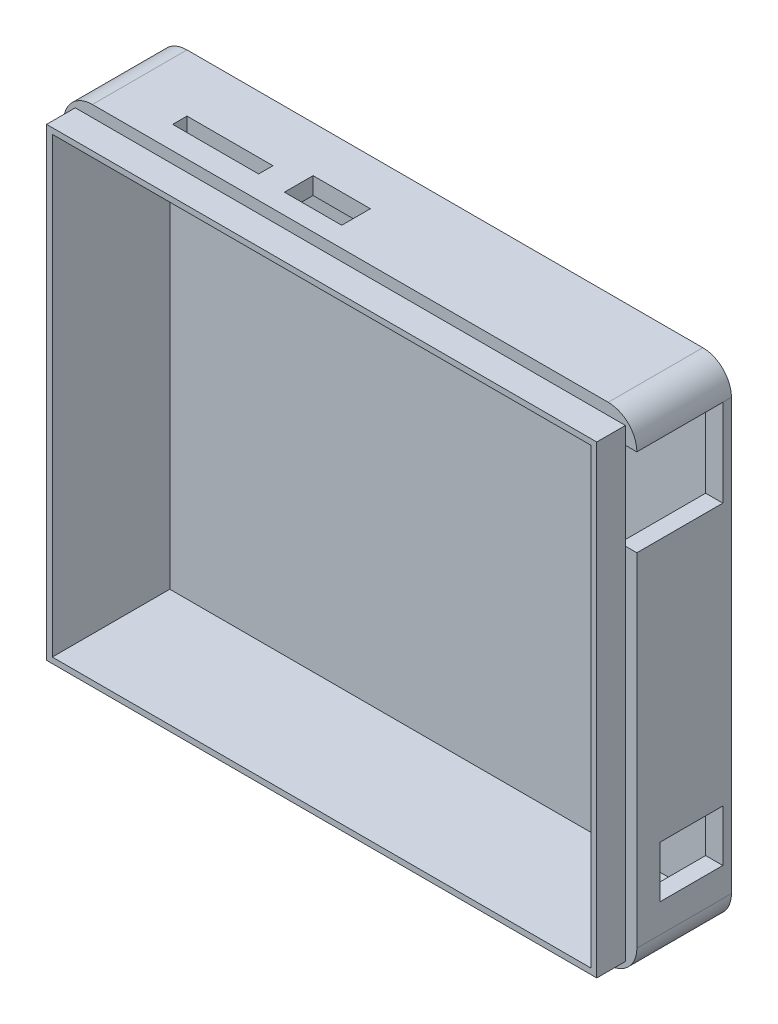
from build123d import *

# Parameters (mm, degrees)
SKETCH1_W           = 100
SKETCH1_H           = 85
BOSS_EXTRUDE2_DEPTH = 20
SKETCH3_W           = 100
SKETCH3_H           = 85
SKETCH3_W_2         = 96
SKETCH3_H_2         = 81
CUT_EXTRUDE1_DEPTH  = 5
SKETCH4_W           = 94
SKETCH4_H           = 79
CUT_EXTRUDE2_DEPTH  = 19
SKETCH9_W           = 100
SKETCH9_H           = 85
BOSS_EXTRUDE3_DEPTH = 1.5
SKETCH10_W          = 94
SKETCH10_H          = 79
CUT_EXTRUDE5_DEPTH  = 1.5
SKETCH11_W          = 11
SKETCH11_H          = 9
CUT_EXTRUDE7_DEPTH  = 50
SKETCH12_W          = 15
SKETCH12_H          = 15.24
CUT_EXTRUDE8_DEPTH  = 50
SKETCH13_W          = 15
SKETCH13_H          = 2.5
CUT_EXTRUDE9_DEPTH  = 50
SKETCH14_W          = 10
SKETCH14_H          = 5
CUT_EXTRUDE10_DEPTH = 50
FILLET1_R           = 5


with BuildPart() as part:
    # Sketch1 → Boss-Extrude2 (new body)
    with BuildSketch(Plane.XY):
        Rectangle(SKETCH1_W, SKETCH1_H)
    extrude(amount=BOSS_EXTRUDE2_DEPTH)

    # Sketch3 → Cut-Extrude1 (cut)
    with BuildSketch(Plane.XY.offset(20)):
        Rectangle(SKETCH3_W, SKETCH3_H)
        Rectangle(SKETCH3_W_2, SKETCH3_H_2, mode=Mode.SUBTRACT)
    extrude(amount=-CUT_EXTRUDE1_DEPTH, mode=Mode.SUBTRACT)

    # Sketch4 → Cut-Extrude2 (cut)
    with BuildSketch(Plane.XY.offset(20)):
        Rectangle(SKETCH4_W, SKETCH4_H)
    extrude(amount=-CUT_EXTRUDE2_DEPTH, mode=Mode.SUBTRACT)

    # Sketch9 → Boss-Extrude3 (add)
    with BuildSketch(Plane(origin=(0, 0, 0), x_dir=(-1, 0, 0), z_dir=(0, 0, -1))):
        Rectangle(SKETCH9_W, SKETCH9_H)
    extrude(amount=BOSS_EXTRUDE3_DEPTH)

    # Sketch10 → Cut-Extrude5 (cut)
    with BuildSketch(Plane.XY.offset(1)):
        Rectangle(SKETCH10_W, SKETCH10_H)
    extrude(amount=-CUT_EXTRUDE5_DEPTH, mode=Mode.SUBTRACT)

    # Sketch11 → Cut-Extrude7 (cut)
    with BuildSketch(Plane(origin=(50, 0, 0), x_dir=(0, 0, -1), z_dir=(1, 0, 0))):
        with Locations((-5.5, -28)):
            Rectangle(SKETCH11_W, SKETCH11_H)
    extrude(amount=-CUT_EXTRUDE7_DEPTH, mode=Mode.SUBTRACT)

    # Sketch12 → Cut-Extrude8 (cut)
    with BuildSketch(Plane(origin=(50, 0, 0), x_dir=(0, 0, -1), z_dir=(1, 0, 0))):
        with Locations((-7.5, 29.88)):
            Rectangle(SKETCH12_W, SKETCH12_H)
    extrude(amount=-CUT_EXTRUDE8_DEPTH, mode=Mode.SUBTRACT)

    # Sketch13 → Cut-Extrude9 (cut)
    with BuildSketch(Plane(origin=(0, 42.5, 0), x_dir=(1, 0, 0), z_dir=(0, 1, 0))):
        with Locations((-27.5, -9.75)):
            Rectangle(SKETCH13_W, SKETCH13_H)
    extrude(amount=-CUT_EXTRUDE9_DEPTH, mode=Mode.SUBTRACT)

    # Sketch14 → Cut-Extrude10 (cut)
    with BuildSketch(Plane(origin=(0, 42.5, 0), x_dir=(1, 0, 0), z_dir=(0, 1, 0))):
        with Locations((-10, -9)):
            Rectangle(SKETCH14_W, SKETCH14_H)
    extrude(amount=-CUT_EXTRUDE10_DEPTH, mode=Mode.SUBTRACT)

    # Fillet1
    fillet1_edges = [part.edges().sort_by_distance(p)[0] for p in [
        (50, -42.5, 6.75),
        (-50, -42.5, 6.75),
        (-50, 42.5, 6.75),
        (50, 42.5, 6.75),
    ]]
    fillet(fillet1_edges, radius=FILLET1_R)


solid = part.part
